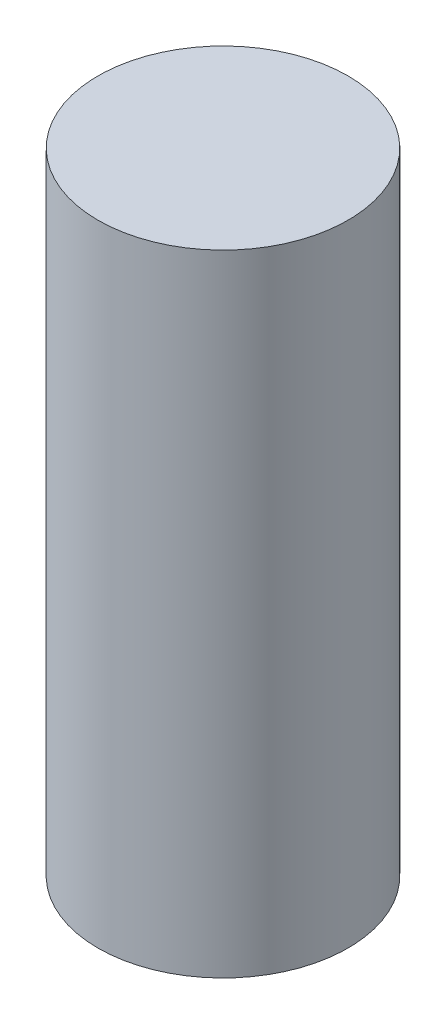
from build123d import *

# Parameters (mm, degrees)
SKETCH2_R           = 18.034
BOSS_EXTRUDE1_DEPTH = 90.932


with BuildPart() as part:
    # Sketch2 → Boss-Extrude1 (new body)
    with BuildSketch(Plane(origin=(0, 0, 0), x_dir=(1, 0, 0), z_dir=(0, 1, 0))):
        Circle(SKETCH2_R)
    extrude(amount=BOSS_EXTRUDE1_DEPTH)


solid = part.part
